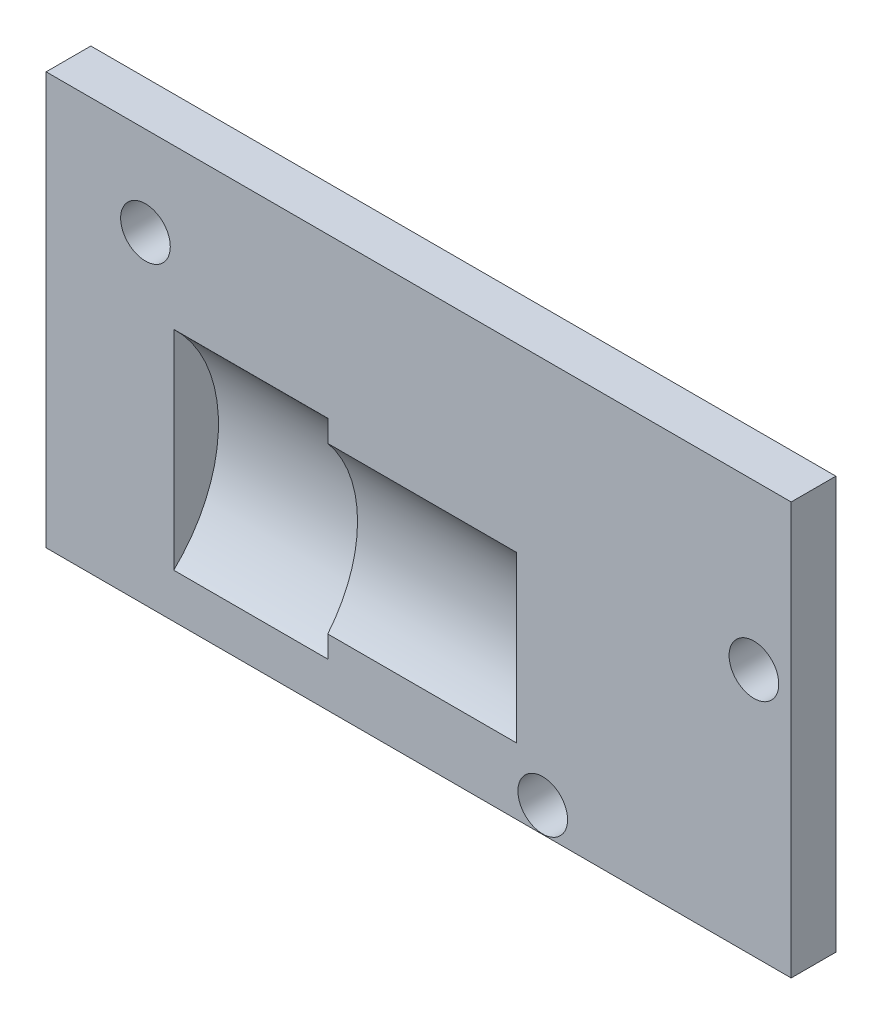
from build123d import *

# Parameters (mm, degrees)
SKETCH1_W            = 15
SKETCH1_H            = 8.3
SKETCH1_R            = 0.5
FRONT_FACE_EXT_DEPTH = 0.9
BOSS_EXTRUDE1_START  = -0.3
BOSS_EXTRUDE1_DEPTH  = 8.4
CUT_EXTRUDE5_START   = -1
CUT_EXTRUDE5_DEPTH   = 3.1
CUT_EXTRUDE6_DEPTH   = 3.8


with BuildPart() as part:
    # Sketch1 → Front Face Ext (new body)
    with BuildSketch(Plane.XY):
        Rectangle(SKETCH1_W, SKETCH1_H)
        with Locations((-5.5, 2.35)):
            Circle(SKETCH1_R, mode=Mode.SUBTRACT)
        with Locations((6.75, 0.85)):
            Circle(SKETCH1_R, mode=Mode.SUBTRACT)
        with Locations((2.498361092, -3.64)):
            Circle(SKETCH1_R, mode=Mode.SUBTRACT)
    extrude(amount=FRONT_FACE_EXT_DEPTH)

    # Sketch3 → Boss-Extrude1 (add)
    with BuildSketch(Plane.ZY.offset(5.93).offset(BOSS_EXTRUDE1_START)):
        with BuildLine():
            Line((0, 0.65), (0, -2.96))
            ThreePointArc((0, -2.96), (-0.501337798, -1.155), (0, 0.65))
        make_face()
    extrude(amount=-BOSS_EXTRUDE1_DEPTH)

    # Sketch4 → Cut-Extrude5 (cut)
    with BuildSketch(Plane.ZY.offset(5.93).offset(CUT_EXTRUDE5_START)):
        with BuildLine():
            Line((0.9, 0.945), (0.9, -3.255))
            ThreePointArc((0.9, -3.255), (0, -1.155), (0.9, 0.945))
        make_face()
    extrude(amount=-CUT_EXTRUDE5_DEPTH, mode=Mode.SUBTRACT)

    # Sketch6 → Cut-Extrude6 (cut)
    with BuildSketch(Plane.ZY.offset(1.83)):
        with BuildLine():
            Line((0.9, 0.506324773), (0.9, -2.816324773))
            ThreePointArc((0.9, -2.816324773), (0.3, -1.155), (0.9, 0.506324773))
        make_face()
    extrude(amount=-CUT_EXTRUDE6_DEPTH, mode=Mode.SUBTRACT)


solid = part.part
